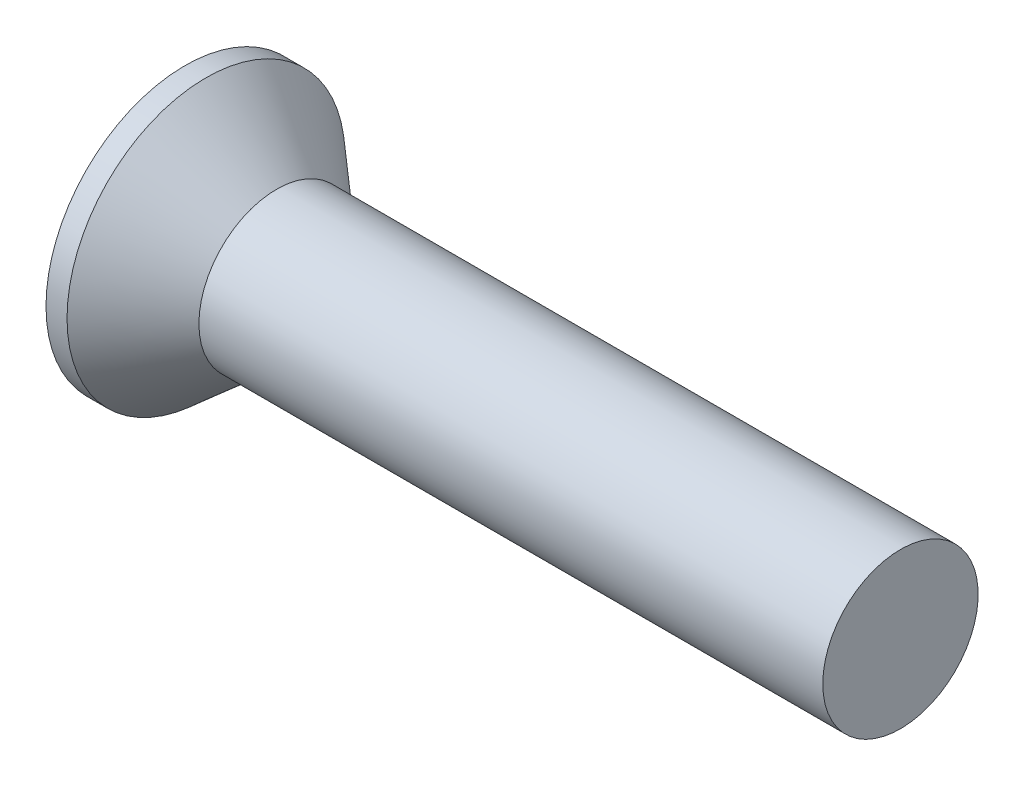
from build123d import *


with BuildPart() as part:
    # BodySke → Base-Revolve (revolve)
    with BuildSketch(Plane.XY):
        Polygon((0, 0), (0, 4.318), (0.653348184, 4.318), (2.8448, 2.413), (22.225, 2.413), (22.225, 0), align=None)
    revolve(axis=Axis((-6.35, 0, 0), (1, 0, 0)))


solid = part.part
